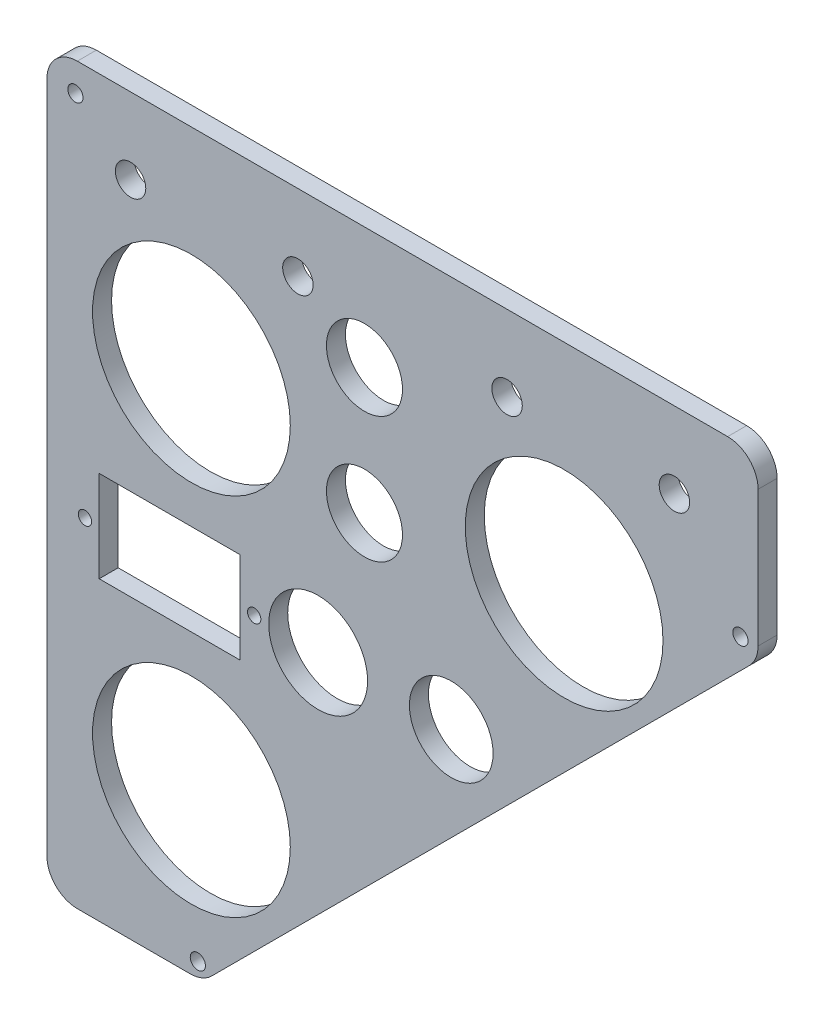
from build123d import *

# Parameters (mm, degrees)
ESTRUSIONE_ESTRUSIONE1_DEPTH    = 5
SCHIZZO5_R                      = 1.75
SCHIZZO5_R_2                    = 10
SCHIZZO5_R_3                    = 11
SCHIZZO5_R_4                    = 13
SCHIZZO5_R_5                    = 26
SCHIZZO5_W                      = 37
SCHIZZO5_H                      = 24
TAGLIO_ESTRUSIONE2_DEPTH        = 7
SCHIZZO6_R                      = 4
TAGLIO_ESTRUSIONE3_DEPTH        = 10
FORI_ALESATO_4_0MM1_D           = 4
FORI_ALESATO_4_0MM1_DEPTH       = 40.6
FORI_ALESATO_4_0MM1_CSINK_D     = 4.05
FORI_ALESATO_4_0MM1_CSINK_ANGLE = 90
FORI_ALESATO_4_0MM1_TIP         = 1.201721238


with BuildPart() as part:
    # Schizzo1 → Estrusione-Estrusione1 (new body)
    with BuildSketch(Plane.XY):
        with BuildLine():
            Line((0, 8), (0, 185))
            ThreePointArc((0, 185), (2.343145751, 190.656854249), (8, 193))
            Line((8, 193), (179, 193))
            ThreePointArc((179, 193), (184.656854249, 190.656854249), (187, 185))
            Line((187, 185), (187, 149.313708499))
            ThreePointArc((187, 149.313708499), (186.39103626, 146.25224104), (184.656854249, 143.656854249))
            Line((184.656854249, 143.656854249), (43.343145751, 2.343145751))
            ThreePointArc((43.343145751, 2.343145751), (40.74775896, 0.60896374), (37.686291501, 0))
            Line((37.686291501, 0), (8, 0))
            ThreePointArc((8, 0), (2.343145751, 2.343145751), (0, 8))
        make_face()
    extrude(amount=ESTRUSIONE_ESTRUSIONE1_DEPTH)

    # Schizzo5 → Taglio-Estrusione2 (cut)
    with BuildSketch(Plane.XY.offset(5)):
        with Locations((10, 90)):
            Circle(SCHIZZO5_R)
        with Locations((54.5, 90)):
            Circle(SCHIZZO5_R)
        with Locations((83.5, 161)):
            Circle(SCHIZZO5_R_2)
        with Locations((106.319509986, 90)):
            Circle(SCHIZZO5_R_3)
        with Locations((71.319509986, 90)):
            Circle(SCHIZZO5_R_4)
        with Locations((38, 138)):
            Circle(SCHIZZO5_R_5)
        with Locations((136, 138)):
            Circle(SCHIZZO5_R_5)
        with Locations((38, 42)):
            Circle(SCHIZZO5_R_5)
        with Locations((83.5, 127.850051573)):
            Circle(SCHIZZO5_R_2)
        with Locations((32.25, 90)):
            Rectangle(SCHIZZO5_W, SCHIZZO5_H)
    extrude(amount=-TAGLIO_ESTRUSIONE2_DEPTH, mode=Mode.SUBTRACT)

    # Schizzo6 → Taglio-Estrusione3 (cut)
    with BuildSketch(Plane.XY.offset(5)):
        with Locations((22, 173)):
            Circle(SCHIZZO6_R)
        with Locations((66, 173)):
            Circle(SCHIZZO6_R)
        with Locations((121, 173)):
            Circle(SCHIZZO6_R)
        with Locations((165, 173)):
            Circle(SCHIZZO6_R)
    extrude(amount=-TAGLIO_ESTRUSIONE3_DEPTH, mode=Mode.SUBTRACT)

    # Fori Alesato Ø4.0mm1
    with Locations(Plane(origin=(0, 0, 0), x_dir=(-1, 0, 0), z_dir=(0, 0, -1))):
        with Locations((-182.36, 149.12), (-7.5, 185.4), (-39.69, 3.83)):
            CounterSinkHole(FORI_ALESATO_4_0MM1_D / 2, FORI_ALESATO_4_0MM1_CSINK_D / 2, depth=FORI_ALESATO_4_0MM1_DEPTH, counter_sink_angle=FORI_ALESATO_4_0MM1_CSINK_ANGLE)
            with Locations((0, 0, -(FORI_ALESATO_4_0MM1_DEPTH + FORI_ALESATO_4_0MM1_TIP / 2))):  # 118° drill point
                Cone(0, FORI_ALESATO_4_0MM1_D / 2, FORI_ALESATO_4_0MM1_TIP, mode=Mode.SUBTRACT)


solid = part.part
